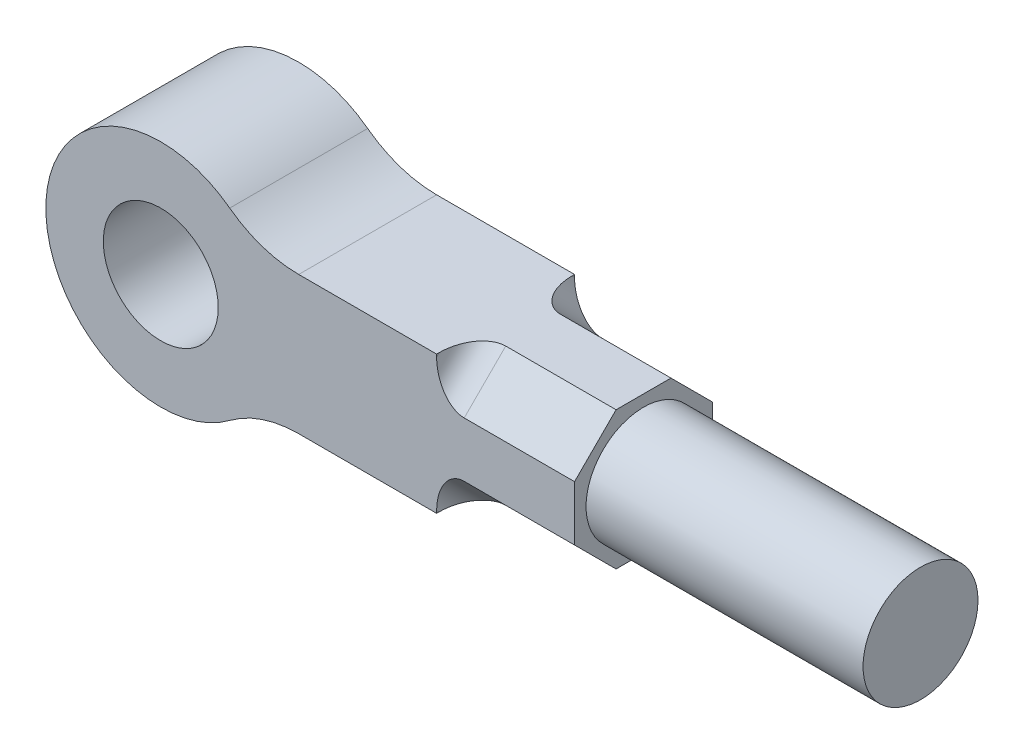
from build123d import *

# Parameters (mm, degrees)
SKETCH1_R           = 250
BOSS_EXTRUDE1_DEPTH = 600
CUT_EXTRUDE2_DEPTH  = 600
SKETCH2_4_R         = 250
BOSS_EXTRUDE2_DEPTH = 1205
FILLET1_R           = 120


with BuildPart() as part:
    # Sketch1 → Boss-Extrude1 (new body)
    with BuildSketch(Plane.XY):
        with BuildLine():
            Line((600, 300), (1800, 300))
            Line((1800, 300), (1800, -300))
            Line((1800, -300), (600, -300))
            ThreePointArc((600, -300), (441.886116992, -325.658350975), (300, -400))
            ThreePointArc((300, -400), (-500, 0), (300, 400))
            ThreePointArc((300, 400), (441.886116992, 325.658350975), (600, 300))
        make_face()
        Circle(SKETCH1_R, mode=Mode.SUBTRACT)
    extrude(amount=BOSS_EXTRUDE1_DEPTH)

    # Sketch2 → Cut-Extrude2 (cut)
    with BuildSketch(Plane(origin=(1800, 0, 0), x_dir=(0, 0, -1), z_dir=(1, 0, 0))):
        Polygon((-600, 119.4), (-419.4, 300), (-600, 300), align=None)
        Polygon((0, 300), (-180.6, 300), (0, 119.4), align=None)
        Polygon((0, -300), (0, -119.4), (-180.6, -300), align=None)
        Polygon((-419.4, -300), (-600, -119.4), (-600, -300), align=None)
    extrude(amount=-CUT_EXTRUDE2_DEPTH, mode=Mode.SUBTRACT)

    # Sketch2_4 → Boss-Extrude2 (add)
    with BuildSketch(Plane(origin=(1800, 0, 0), x_dir=(0, 0, -1), z_dir=(1, 0, 0))):
        with Locations((-300, 0)):
            Circle(SKETCH2_4_R)
    extrude(amount=BOSS_EXTRUDE2_DEPTH)

    # Fillet1
    fillet1_edges = [part.edges().sort_by_distance(p)[0] for p in [
        (1200, -209.7, 509.7),
        (1200, -209.7, 90.3),
        (1200, 209.7, 90.3),
        (1200, 209.7, 509.7),
    ]]
    fillet(fillet1_edges, radius=FILLET1_R)


solid = part.part
